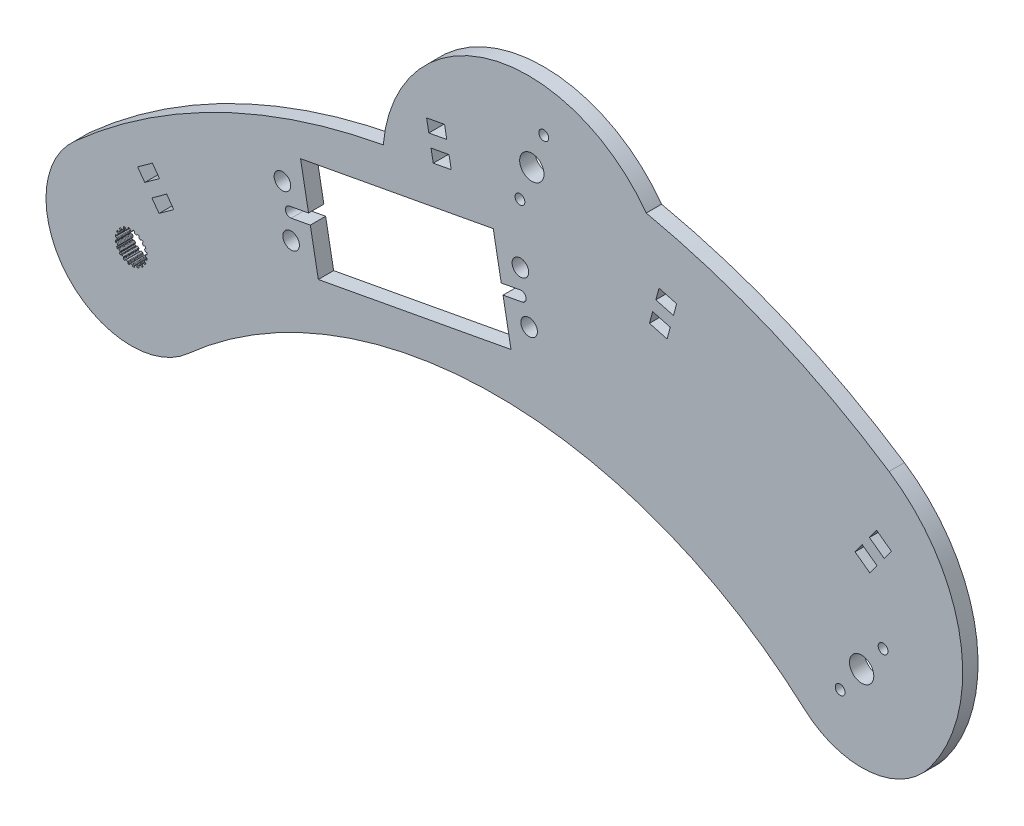
from build123d import *

# Parameters (mm, degrees)
BOSS_EXTRUDE1_DEPTH = 3.2004
SKETCH4_R           = 2.54
BOSS_EXTRUDE3_DEPTH = 3.2004
SKETCH2_R           = 1.7272
SKETCH2_R_2         = 2.54
CUT_EXTRUDE1_DEPTH  = 3.2004
SKETCH5_R           = 1.025
CUT_EXTRUDE2_DEPTH  = 3.2004
SKETCH6_R           = 1.025
CUT_EXTRUDE3_DEPTH  = 3.2004
BOSS_EXTRUDE4_DEPTH = 3.2004
CUT_EXTRUDE4_DEPTH  = 3.2004
CUT_EXTRUDE5_DEPTH  = 3.2004


with BuildPart() as part:
    # Sketch1 → Boss-Extrude1 (new body)
    with BuildSketch(Plane.XY):
        with BuildLine():
            ThreePointArc((-11.875315661, 13.236894431), (76.2, 46.954576728), (164.275315661, 13.236894431))
            ThreePointArc((164.275315661, 13.236894431), (165.636894431, -11.875315661), (140.524684339, -13.236894431))
            ThreePointArc((140.524684339, -13.236894431), (76.2, 11.388385128), (11.875315661, -13.236894431))
            ThreePointArc((11.875315661, -13.236894431), (-13.236894431, -11.875315661), (-11.875315661, 13.236894431))
        make_face()
        with BuildLine():
            Line((-0.106949245, 2.969874934), (0.106949245, 2.969874934))
            ThreePointArc((0.106949245, 2.969874934), (0.196343213, 2.986924176), (0.253739238, 3.057547504))
            Line((0.253739238, 3.057547504), (0.315888147, 3.237526941))
            ThreePointArc((0.315888147, 3.237526941), (0.359032156, 3.298322911), (0.4281449, 3.326269005))
            Line((0.4281449, 3.326269005), (0.620027588, 3.2937547))
            ThreePointArc((0.620027588, 3.2937547), (0.689621142, 3.24802576), (0.718272212, 3.169836791))
            Line((0.718272212, 3.169836791), (0.724389167, 2.979527391))
            ThreePointArc((0.724389167, 2.979527391), (0.750934762, 2.9040661), (0.816027049, 2.857568043))
            Line((0.816027049, 2.857568043), (1.019456602, 2.791469774))
            ThreePointArc((1.019456602, 2.791469774), (1.109743823, 2.780060312), (1.186154496, 2.829490741))
            Line((1.186154496, 2.829490741), (1.300878326, 2.981456288))
            ThreePointArc((1.300878326, 2.981456288), (1.360697704, 3.02594446), (1.435063648, 3.031165762))
            Line((1.435063648, 3.031165762), (1.607507455, 2.940947809))
            ThreePointArc((1.607507455, 2.940947809), (1.659563839, 2.875951412), (1.662650905, 2.792735615))
            Line((1.662650905, 2.792735615), (1.609659636, 2.609850378))
            ThreePointArc((1.609659636, 2.609850378), (1.611587176, 2.529879385), (1.659124931, 2.465542482))
            Line((1.659124931, 2.465542482), (1.832172444, 2.339816104))
            ThreePointArc((1.832172444, 2.339816104), (1.914514976, 2.301064775), (2.002460687, 2.32446371))
            Line((2.002460687, 2.32446371), (2.158529469, 2.433539921))
            ThreePointArc((2.158529469, 2.433539921), (2.229168681, 2.457365482), (2.301508367, 2.439350895))
            Line((2.301508367, 2.439350895), (2.437633293, 2.300260456))
            ThreePointArc((2.437633293, 2.300260456), (2.467056864, 2.222358901), (2.444277744, 2.14226202))
            Line((2.444277744, 2.14226202), (2.337365406, 1.984703026))
            ThreePointArc((2.337365406, 1.984703026), (2.314486209, 1.908050449), (2.339816104, 1.832172444))
            Line((2.339816104, 1.832172444), (2.465542482, 1.659124931))
            ThreePointArc((2.465542482, 1.659124931), (2.531880064, 1.596824985), (2.622752074, 1.591901975))
            Line((2.622752074, 1.591901975), (2.804888709, 1.64741171))
            ThreePointArc((2.804888709, 1.64741171), (2.879433095, 1.648242449), (2.942665411, 1.608755366))
            Line((2.942665411, 1.608755366), (3.0291466, 1.434407582))
            ThreePointArc((3.0291466, 1.434407582), (3.033057175, 1.351226417), (2.986641646, 1.282088892))
            Line((2.986641646, 1.282088892), (2.836273564, 1.165279113))
            ThreePointArc((2.836273564, 1.165279113), (2.790827206, 1.099448241), (2.791469774, 1.019456602))
            Line((2.791469774, 1.019456602), (2.857568043, 0.816027049))
            ThreePointArc((2.857568043, 0.816027049), (2.901407091, 0.736276839), (2.986310214, 0.703513784))
            Line((2.986310214, 0.703513784), (3.1766859, 0.700023363))
            ThreePointArc((3.1766859, 0.700023363), (3.247838536, 0.677777961), (3.295773863, 0.620683653))
            Line((3.295773863, 0.620683653), (3.324145932, 0.4281449))
            ThreePointArc((3.324145932, 0.4281449), (3.302160717, 0.347826477), (3.236652255, 0.29641597))
            Line((3.236652255, 0.29641597), (3.057547504, 0.231789562))
            ThreePointArc((3.057547504, 0.231789562), (2.993982591, 0.183224379), (2.969874934, 0.106949245))
            Line((2.969874934, 0.106949245), (2.969874934, -0.106949245))
            ThreePointArc((2.969874934, -0.106949245), (2.986924176, -0.196343213), (3.057547504, -0.253739238))
            Line((3.057547504, -0.253739238), (3.237526941, -0.315888147))
            ThreePointArc((3.237526941, -0.315888147), (3.298322911, -0.359032156), (3.326269005, -0.4281449))
            Line((3.326269005, -0.4281449), (3.2937547, -0.620027588))
            ThreePointArc((3.2937547, -0.620027588), (3.24802576, -0.689621142), (3.169836791, -0.718272212))
            Line((3.169836791, -0.718272212), (2.979527391, -0.724389167))
            ThreePointArc((2.979527391, -0.724389167), (2.9040661, -0.750934762), (2.857568043, -0.816027049))
            Line((2.857568043, -0.816027049), (2.791469774, -1.019456602))
            ThreePointArc((2.791469774, -1.019456602), (2.780060312, -1.109743823), (2.829490741, -1.186154496))
            Line((2.829490741, -1.186154496), (2.981456288, -1.300878326))
            ThreePointArc((2.981456288, -1.300878326), (3.02594446, -1.360697704), (3.031165762, -1.435063648))
            Line((3.031165762, -1.435063648), (2.940947809, -1.607507455))
            ThreePointArc((2.940947809, -1.607507455), (2.875951412, -1.659563839), (2.792735615, -1.662650905))
            Line((2.792735615, -1.662650905), (2.609850378, -1.609659636))
            ThreePointArc((2.609850378, -1.609659636), (2.529879385, -1.611587176), (2.465542482, -1.659124931))
            Line((2.465542482, -1.659124931), (2.339816104, -1.832172444))
            ThreePointArc((2.339816104, -1.832172444), (2.301064775, -1.914514976), (2.32446371, -2.002460687))
            Line((2.32446371, -2.002460687), (2.433539921, -2.158529469))
            ThreePointArc((2.433539921, -2.158529469), (2.457365482, -2.229168681), (2.439350895, -2.301508367))
            Line((2.439350895, -2.301508367), (2.300260456, -2.437633293))
            ThreePointArc((2.300260456, -2.437633293), (2.222358901, -2.467056864), (2.14226202, -2.444277744))
            Line((2.14226202, -2.444277744), (1.984703026, -2.337365406))
            ThreePointArc((1.984703026, -2.337365406), (1.908050449, -2.314486209), (1.832172444, -2.339816104))
            Line((1.832172444, -2.339816104), (1.659124931, -2.465542482))
            ThreePointArc((1.659124931, -2.465542482), (1.596824985, -2.531880064), (1.591901975, -2.622752074))
            Line((1.591901975, -2.622752074), (1.64741171, -2.804888709))
            ThreePointArc((1.64741171, -2.804888709), (1.648242449, -2.879433095), (1.608755366, -2.942665411))
            Line((1.608755366, -2.942665411), (1.434407582, -3.0291466))
            ThreePointArc((1.434407582, -3.0291466), (1.351226417, -3.033057175), (1.282088892, -2.986641646))
            Line((1.282088892, -2.986641646), (1.165279113, -2.836273564))
            ThreePointArc((1.165279113, -2.836273564), (1.099448241, -2.790827206), (1.019456602, -2.791469774))
            Line((1.019456602, -2.791469774), (0.816027049, -2.857568043))
            ThreePointArc((0.816027049, -2.857568043), (0.736276839, -2.901407091), (0.703513784, -2.986310214))
            Line((0.703513784, -2.986310214), (0.700023363, -3.1766859))
            ThreePointArc((0.700023363, -3.1766859), (0.677777961, -3.247838536), (0.620683653, -3.295773863))
            Line((0.620683653, -3.295773863), (0.4281449, -3.324145932))
            ThreePointArc((0.4281449, -3.324145932), (0.347826477, -3.302160717), (0.29641597, -3.236652255))
            Line((0.29641597, -3.236652255), (0.231789562, -3.057547504))
            ThreePointArc((0.231789562, -3.057547504), (0.183224379, -2.993982591), (0.106949245, -2.969874934))
            Line((0.106949245, -2.969874934), (-0.106949245, -2.969874934))
            ThreePointArc((-0.106949245, -2.969874934), (-0.196343213, -2.986924176), (-0.253739238, -3.057547504))
            Line((-0.253739238, -3.057547504), (-0.315888147, -3.237526941))
            ThreePointArc((-0.315888147, -3.237526941), (-0.359032156, -3.298322911), (-0.4281449, -3.326269005))
            Line((-0.4281449, -3.326269005), (-0.620027588, -3.2937547))
            ThreePointArc((-0.620027588, -3.2937547), (-0.689621142, -3.24802576), (-0.718272212, -3.169836791))
            Line((-0.718272212, -3.169836791), (-0.724389167, -2.979527391))
            ThreePointArc((-0.724389167, -2.979527391), (-0.750934762, -2.9040661), (-0.816027049, -2.857568043))
            Line((-0.816027049, -2.857568043), (-1.019456602, -2.791469774))
            ThreePointArc((-1.019456602, -2.791469774), (-1.109743823, -2.780060312), (-1.186154496, -2.829490741))
            Line((-1.186154496, -2.829490741), (-1.300878326, -2.981456288))
            ThreePointArc((-1.300878326, -2.981456288), (-1.360697704, -3.02594446), (-1.435063648, -3.031165762))
            Line((-1.435063648, -3.031165762), (-1.607507455, -2.940947809))
            ThreePointArc((-1.607507455, -2.940947809), (-1.659563839, -2.875951412), (-1.662650905, -2.792735615))
            Line((-1.662650905, -2.792735615), (-1.609659636, -2.609850378))
            ThreePointArc((-1.609659636, -2.609850378), (-1.611587176, -2.529879385), (-1.659124931, -2.465542482))
            Line((-1.659124931, -2.465542482), (-1.832172444, -2.339816104))
            ThreePointArc((-1.832172444, -2.339816104), (-1.914514976, -2.301064775), (-2.002460687, -2.32446371))
            Line((-2.002460687, -2.32446371), (-2.158529469, -2.433539921))
            ThreePointArc((-2.158529469, -2.433539921), (-2.229168681, -2.457365482), (-2.301508367, -2.439350895))
            Line((-2.301508367, -2.439350895), (-2.437633293, -2.300260456))
            ThreePointArc((-2.437633293, -2.300260456), (-2.467056864, -2.222358901), (-2.444277744, -2.14226202))
            Line((-2.444277744, -2.14226202), (-2.337365406, -1.984703026))
            ThreePointArc((-2.337365406, -1.984703026), (-2.314486209, -1.908050449), (-2.339816104, -1.832172444))
            Line((-2.339816104, -1.832172444), (-2.465542482, -1.659124931))
            ThreePointArc((-2.465542482, -1.659124931), (-2.531880064, -1.596824985), (-2.622752074, -1.591901975))
            Line((-2.622752074, -1.591901975), (-2.804888709, -1.64741171))
            ThreePointArc((-2.804888709, -1.64741171), (-2.879433095, -1.648242449), (-2.942665411, -1.608755366))
            Line((-2.942665411, -1.608755366), (-3.0291466, -1.434407582))
            ThreePointArc((-3.0291466, -1.434407582), (-3.033057175, -1.351226417), (-2.986641646, -1.282088892))
            Line((-2.986641646, -1.282088892), (-2.836273564, -1.165279113))
            ThreePointArc((-2.836273564, -1.165279113), (-2.790827206, -1.099448241), (-2.791469774, -1.019456602))
            Line((-2.791469774, -1.019456602), (-2.857568043, -0.816027049))
            ThreePointArc((-2.857568043, -0.816027049), (-2.901407091, -0.736276839), (-2.986310214, -0.703513784))
            Line((-2.986310214, -0.703513784), (-3.1766859, -0.700023363))
            ThreePointArc((-3.1766859, -0.700023363), (-3.247838536, -0.677777961), (-3.295773863, -0.620683653))
            Line((-3.295773863, -0.620683653), (-3.324145932, -0.4281449))
            ThreePointArc((-3.324145932, -0.4281449), (-3.302160717, -0.347826477), (-3.236652255, -0.29641597))
            Line((-3.236652255, -0.29641597), (-3.057547504, -0.231789562))
            ThreePointArc((-3.057547504, -0.231789562), (-2.993982591, -0.183224379), (-2.969874934, -0.106949245))
            Line((-2.969874934, -0.106949245), (-2.969874934, 0.106949245))
            ThreePointArc((-2.969874934, 0.106949245), (-2.986924176, 0.196343213), (-3.057547504, 0.253739238))
            Line((-3.057547504, 0.253739238), (-3.237526941, 0.315888147))
            ThreePointArc((-3.237526941, 0.315888147), (-3.298322911, 0.359032156), (-3.326269005, 0.4281449))
            Line((-3.326269005, 0.4281449), (-3.2937547, 0.620027588))
            ThreePointArc((-3.2937547, 0.620027588), (-3.24802576, 0.689621142), (-3.169836791, 0.718272212))
            Line((-3.169836791, 0.718272212), (-2.979527391, 0.724389167))
            ThreePointArc((-2.979527391, 0.724389167), (-2.9040661, 0.750934762), (-2.857568043, 0.816027049))
            Line((-2.857568043, 0.816027049), (-2.791469774, 1.019456602))
            ThreePointArc((-2.791469774, 1.019456602), (-2.780060312, 1.109743823), (-2.829490741, 1.186154496))
            Line((-2.829490741, 1.186154496), (-2.981456288, 1.300878326))
            ThreePointArc((-2.981456288, 1.300878326), (-3.02594446, 1.360697704), (-3.031165762, 1.435063648))
            Line((-3.031165762, 1.435063648), (-2.940947809, 1.607507455))
            ThreePointArc((-2.940947809, 1.607507455), (-2.875951412, 1.659563839), (-2.792735615, 1.662650905))
            Line((-2.792735615, 1.662650905), (-2.609850378, 1.609659636))
            ThreePointArc((-2.609850378, 1.609659636), (-2.529879385, 1.611587176), (-2.465542482, 1.659124931))
            Line((-2.465542482, 1.659124931), (-2.339816104, 1.832172444))
            ThreePointArc((-2.339816104, 1.832172444), (-2.301064775, 1.914514976), (-2.32446371, 2.002460687))
            Line((-2.32446371, 2.002460687), (-2.433539921, 2.158529469))
            ThreePointArc((-2.433539921, 2.158529469), (-2.457365482, 2.229168681), (-2.439350895, 2.301508367))
            Line((-2.439350895, 2.301508367), (-2.300260456, 2.437633293))
            ThreePointArc((-2.300260456, 2.437633293), (-2.222358901, 2.467056864), (-2.14226202, 2.444277744))
            Line((-2.14226202, 2.444277744), (-1.984703026, 2.337365406))
            ThreePointArc((-1.984703026, 2.337365406), (-1.908050449, 2.314486209), (-1.832172444, 2.339816104))
            Line((-1.832172444, 2.339816104), (-1.659124931, 2.465542482))
            ThreePointArc((-1.659124931, 2.465542482), (-1.596824985, 2.531880064), (-1.591901975, 2.622752074))
            Line((-1.591901975, 2.622752074), (-1.64741171, 2.804888709))
            ThreePointArc((-1.64741171, 2.804888709), (-1.648242449, 2.879433095), (-1.608755366, 2.942665411))
            Line((-1.608755366, 2.942665411), (-1.434407582, 3.0291466))
            ThreePointArc((-1.434407582, 3.0291466), (-1.351226417, 3.033057175), (-1.282088892, 2.986641646))
            Line((-1.282088892, 2.986641646), (-1.165279113, 2.836273564))
            ThreePointArc((-1.165279113, 2.836273564), (-1.099448241, 2.790827206), (-1.019456602, 2.791469774))
            Line((-1.019456602, 2.791469774), (-0.816027049, 2.857568043))
            ThreePointArc((-0.816027049, 2.857568043), (-0.736276839, 2.901407091), (-0.703513784, 2.986310214))
            Line((-0.703513784, 2.986310214), (-0.700023363, 3.1766859))
            ThreePointArc((-0.700023363, 3.1766859), (-0.677777961, 3.247838536), (-0.620683653, 3.295773863))
            Line((-0.620683653, 3.295773863), (-0.4281449, 3.324145932))
            ThreePointArc((-0.4281449, 3.324145932), (-0.347826477, 3.302160717), (-0.29641597, 3.236652255))
            Line((-0.29641597, 3.236652255), (-0.231789562, 3.057547504))
            ThreePointArc((-0.231789562, 3.057547504), (-0.183224379, 2.993982591), (-0.106949245, 2.969874934))
        make_face(mode=Mode.SUBTRACT)
    extrude(amount=BOSS_EXTRUDE1_DEPTH)

    # Sketch4 → Boss-Extrude3 (add)
    with BuildSketch(Plane.XY.offset(3.2004)):
        with BuildLine():
            ThreePointArc((52.583038078, 44.822879333), (84.435251709, 72.474885048), (113.22815731, 41.650130056))
            ThreePointArc((113.22815731, 41.650130056), (83.090691179, 46.774450968), (52.583038078, 44.822879333))
        make_face()
        with Locations((83.588077125, 56.286137461)):
            Circle(SKETCH4_R, mode=Mode.SUBTRACT)
    extrude(amount=-BOSS_EXTRUDE3_DEPTH)

    # Sketch2 → Cut-Extrude1 (cut)
    with BuildSketch(Plane.XY.offset(3.2004)):
        with Locations((83.024377165, 27.138095489)):
            Circle(SKETCH2_R)
        with Locations((31.547603929, 27.764049584)):
            Circle(SKETCH2_R)
        with Locations((33.370666119, 17.93163149)):
            Circle(SKETCH2_R)
        with Locations((81.201314975, 36.970513582)):
            Circle(SKETCH2_R)
        with Locations((152.4, 0)):
            Circle(SKETCH2_R_2)
        Polygon((35.32941423, 33.713194018), (75.538104518, 41.168424489), (79.242566863, 21.188951054), (39.033876576, 13.733720584), align=None)
    extrude(amount=-CUT_EXTRUDE1_DEPTH, mode=Mode.SUBTRACT)

    # Sketch5 → Cut-Extrude2 (cut)
    with BuildSketch(Plane(origin=(0, 0, 0), x_dir=(-1, 0, 0), z_dir=(0, 0, -1))):
        with Locations((-86.071808393, 63.301650259)):
            Circle(SKETCH5_R)
        with Locations((-81.104345857, 49.270624662)):
            Circle(SKETCH5_R)
    extrude(amount=-CUT_EXTRUDE2_DEPTH, mode=Mode.SUBTRACT)

    # Sketch6 → Cut-Extrude3 (cut)
    with BuildSketch(Plane.XY.offset(3.2004)):
        with Locations((147.921172235, -5.943605193)):
            Circle(SKETCH6_R)
        with Locations((156.878827765, 5.943605193)):
            Circle(SKETCH6_R)
    extrude(amount=-CUT_EXTRUDE3_DEPTH, mode=Mode.SUBTRACT)

    # Sketch7 → Boss-Extrude4 (add)
    with BuildSketch(Plane.XY):
        with BuildLine():
            ThreePointArc((107.45876177, 59.950720167), (133.790270055, 51.638690278), (158.123143389, 38.586891754))
            ThreePointArc((158.123143389, 38.586891754), (172.994139846, 15.795725761), (166.631162232, -10.663607165))
            ThreePointArc((166.631162232, -10.663607165), (170.097331469, 1.744406806), (164.275315661, 13.236894431))
            ThreePointArc((164.275315661, 13.236894431), (140.344740447, 30.305499753), (113.22815731, 41.650130056))
            ThreePointArc((113.22815731, 41.650130056), (111.8260551, 51.267824259), (107.45876177, 59.950720167))
        make_face()
    extrude(amount=BOSS_EXTRUDE4_DEPTH)

    # Sketch8 → Cut-Extrude4 (cut)
    with BuildSketch(Plane(origin=(0, 0, 0), x_dir=(-1, 0, 0), z_dir=(0, 0, -1))):
        Polygon((-113.802519463, 46.720594144), (-110.12480818, 47.715852764), (-109.461302433, 45.264045242), (-113.139013716, 44.268786622), align=None)
        Polygon((-112.47550797, 41.8169791), (-108.797796687, 42.81223772), (-108.134290941, 40.360430198), (-111.812002223, 39.365171578), align=None)
        Polygon((-158.607972247, 24.409188402), (-155.533693444, 26.659723858), (-154.033336473, 24.610204656), (-157.107615276, 22.3596692), align=None)
        Polygon((-155.607258305, 20.310149998), (-152.532979502, 22.560685454), (-151.032622531, 20.511166252), (-154.106901334, 18.260630795), align=None)
        Polygon((-2.822291485, 13.166112771), (-5.908383045, 15.400422258), (-4.418843388, 17.457816631), (-1.332751827, 15.223507145), align=None)
        Polygon((-5.8013708, 9.051324024), (-8.88746236, 11.28563351), (-7.397922703, 13.343027884), (-4.311831142, 11.108718398), align=None)
        Polygon((-62.094892407, 51.737742802), (-65.841043676, 52.432329492), (-65.377985883, 54.929763671), (-61.631834614, 54.235176982), align=None)
        Polygon((-63.021007993, 46.742874444), (-66.767159262, 47.437461133), (-66.304101469, 49.934895313), (-62.5579502, 49.240308623), align=None)
    extrude(amount=-CUT_EXTRUDE4_DEPTH, mode=Mode.SUBTRACT)

    # Sketch9 → Cut-Extrude5 (cut)
    with BuildSketch(Plane(origin=(0, 0, 0), x_dir=(-1, 0, 0), z_dir=(0, 0, -1))):
        with BuildLine():
            Line((-81.20100726, 32.918553912), (-77.205112573, 32.177661443))
            Line((-77.205112573, 32.177661443), (-77.575558808, 30.1797141))
            Line((-77.575558808, 30.1797141), (-81.571453495, 30.920606569))
            ThreePointArc((-81.571453495, 30.920606569), (-82.385204049, 32.104803358), (-81.20100726, 32.918553912))
        make_face()
        with BuildLine():
            Line((-36.996422286, 24.722430973), (-33.000527599, 23.981538504))
            ThreePointArc((-33.000527599, 23.981538504), (-32.186777045, 22.797341715), (-33.370973834, 21.98359116))
            Line((-33.370973834, 21.98359116), (-37.366868521, 22.724483629))
            Line((-37.366868521, 22.724483629), (-36.996422286, 24.722430973))
        make_face()
    extrude(amount=-CUT_EXTRUDE5_DEPTH, mode=Mode.SUBTRACT)


solid = part.part
